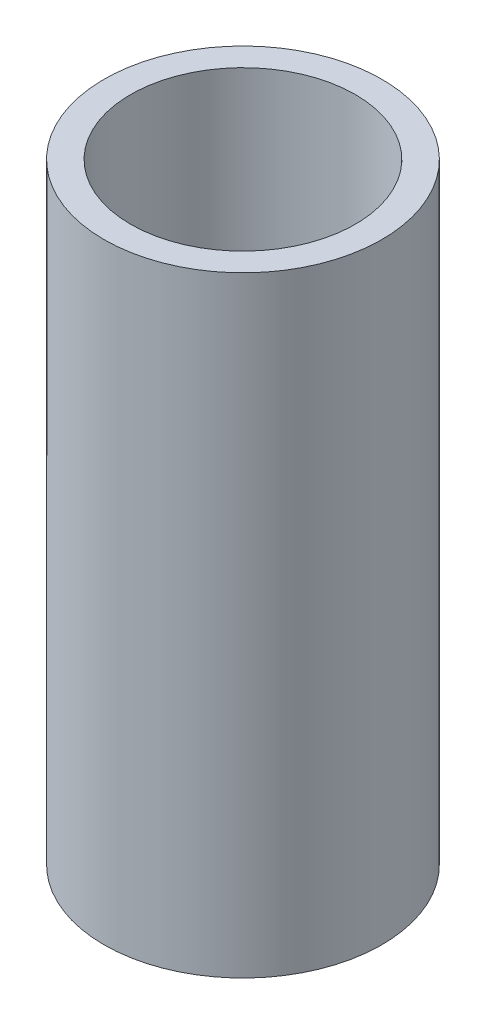
from build123d import *

# Parameters (mm, degrees)
SKETCH1_R           = 34.6583
SKETCH1_R_2         = 28.0416
BOSS_EXTRUDE1_DEPTH = 152.4


with BuildPart() as part:
    # Sketch1 → Boss-Extrude1 (new body)
    with BuildSketch(Plane(origin=(0, 0, 0), x_dir=(1, 0, 0), z_dir=(0, 1, 0))):
        Circle(SKETCH1_R)
        Circle(SKETCH1_R_2, mode=Mode.SUBTRACT)
    extrude(amount=BOSS_EXTRUDE1_DEPTH)


solid = part.part
